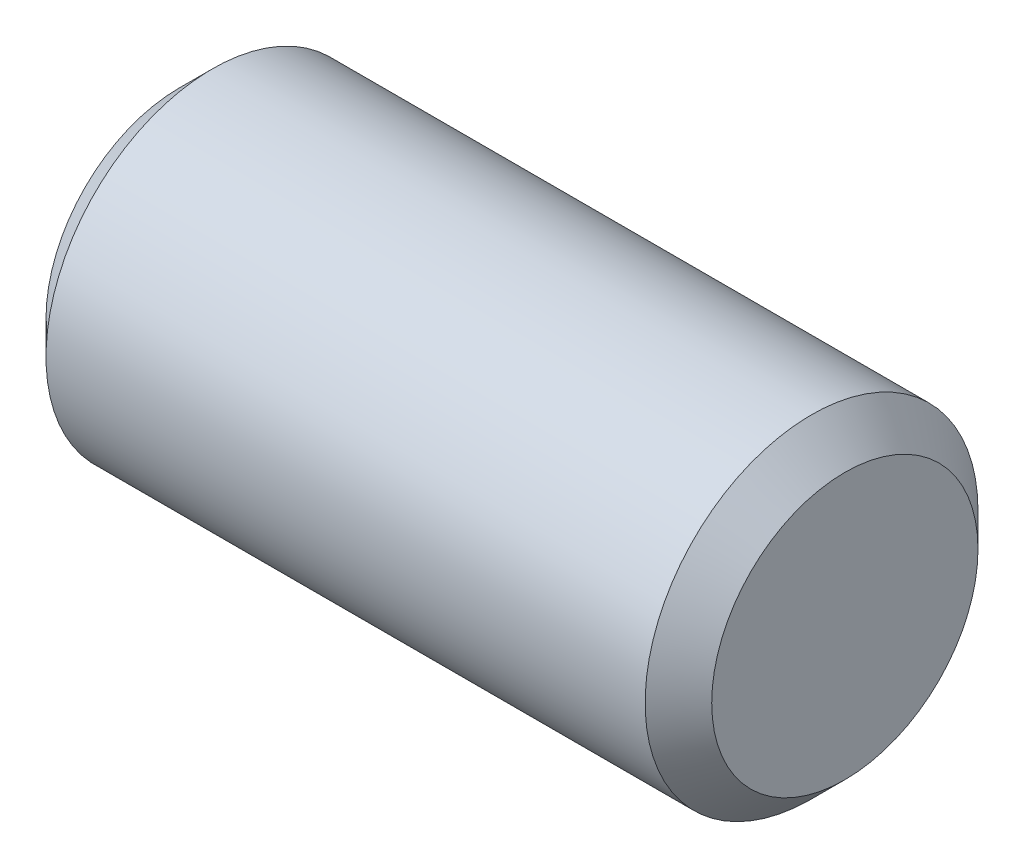
from build123d import *

# Parameters (mm, degrees)
SKETCH2_R           = 2.38125
EXTRUDE1_DEPTH      = 4.7625
EXTRUDE1_DEPTH_BACK = 4.7625
CHAMFER1_SIZE       = 0.47625


with BuildPart() as part:
    # Sketch2 → Extrude1 (new body, two sides)
    with BuildSketch(Plane(origin=(0, 0, 0), x_dir=(0, 0, -1), z_dir=(1, 0, 0))) as extrude1_sk:
        Circle(SKETCH2_R)
    extrude(amount=EXTRUDE1_DEPTH)
    extrude(extrude1_sk.sketch, amount=-EXTRUDE1_DEPTH_BACK)

    # Chamfer1
    chamfer1_edges = [part.edges().sort_by_distance(p)[0] for p in [
        (-4.7625, 0, 2.38125),
        (4.7625, 0, 2.38125),
    ]]
    chamfer(chamfer1_edges, length=CHAMFER1_SIZE)


solid = part.part
